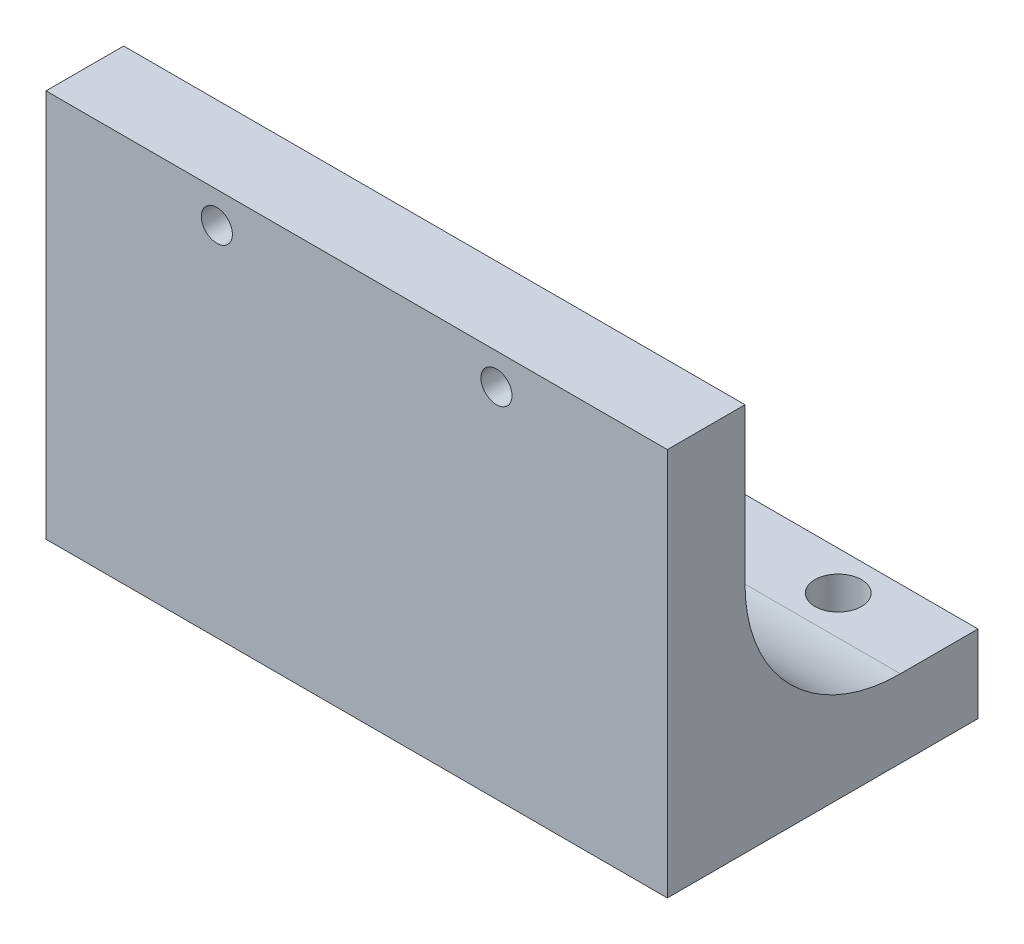
from build123d import *

# Parameters (mm, degrees)
SKETCH1_W           = 40
SKETCH1_H           = 25
SKETCH1_R           = 1
BOSS_EXTRUDE1_DEPTH = 5
SKETCH2_W           = 15
SKETCH2_H           = 5
BOSS_EXTRUDE2_DEPTH = 40
FILLET2_R           = 10
SKETCH8_R           = 1.5
CUT_EXTRUDE1_DEPTH  = 40


with BuildPart() as part:
    # Sketch1 → Boss-Extrude1 (new body)
    with BuildSketch(Plane.XY):
        with Locations((20, 12.5)):
            Rectangle(SKETCH1_W, SKETCH1_H)
        with Locations((11, 23)):
            Circle(SKETCH1_R, mode=Mode.SUBTRACT)
        with Locations((29, 23)):
            Circle(SKETCH1_R, mode=Mode.SUBTRACT)
    extrude(amount=BOSS_EXTRUDE1_DEPTH)

    # Sketch2 → Boss-Extrude2 (add)
    with BuildSketch(Plane.ZY):
        with Locations((-7.5, 2.5)):
            Rectangle(SKETCH2_W, SKETCH2_H)
    extrude(amount=-BOSS_EXTRUDE2_DEPTH)

    # Fillet2
    fillet2_edges = [part.edges().sort_by_distance(p)[0] for p in [
        (20, 5, 0),
    ]]
    fillet(fillet2_edges, radius=FILLET2_R)

    # Sketch8 → Cut-Extrude1 (cut)
    with BuildSketch(Plane(origin=(0, 0, 0), x_dir=(-1, 0, 0), z_dir=(0, -1, 0))):
        with Locations((-6.5, 12.5)):
            Circle(SKETCH8_R)
        with Locations((-33.5, 12.5)):
            Circle(SKETCH8_R)
    extrude(amount=-CUT_EXTRUDE1_DEPTH, mode=Mode.SUBTRACT)


solid = part.part
